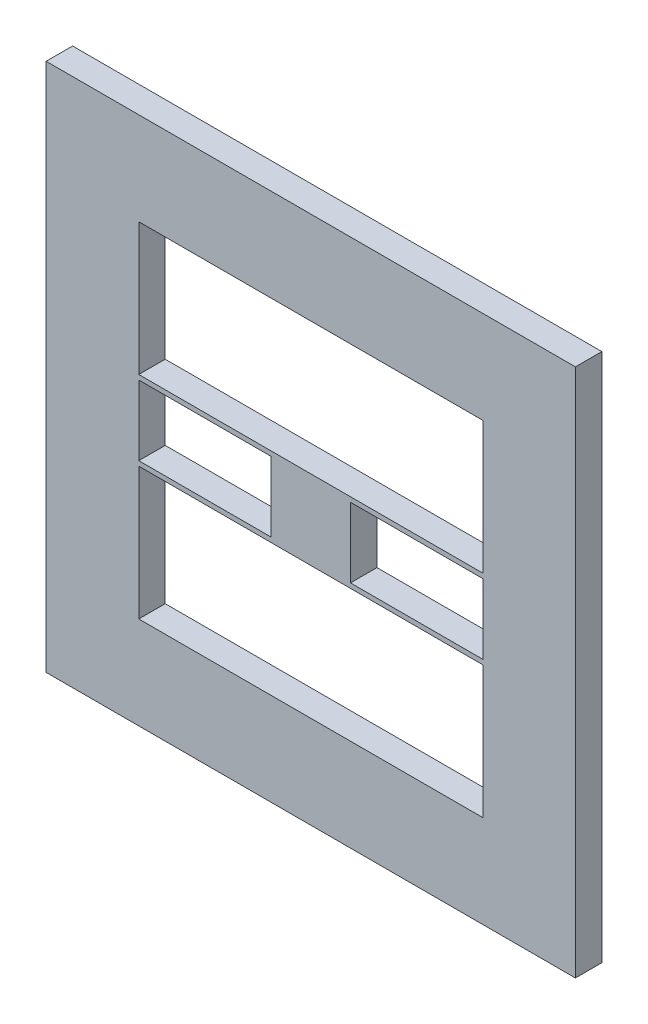
from build123d import *

# Parameters (mm, degrees)
SKETCH1_W      = 0.15
SKETCH1_H      = 0.15
EXTRUDE1_DEPTH = 0.05
SKETCH2_W      = 0.25
SKETCH2_H      = 0.009
EXTRUDE2_DEPTH = 0.05
SKETCH3_W      = 1
SKETCH3_H      = 1
SKETCH3_W_2    = 0.65
SKETCH3_H_2    = 0.65
EXTRUDE3_DEPTH = 0.05


with BuildPart() as part:
    # Sketch1 → Extrude1 (new body)
    with BuildSketch(Plane.XY):
        Rectangle(SKETCH1_W, SKETCH1_H)
    extrude(amount=EXTRUDE1_DEPTH)

    # Sketch2 → Extrude2 (add)
    with BuildSketch(Plane.XY.offset(0.05)):
        with Locations((0.2, 0.0705)):
            Rectangle(SKETCH2_W, SKETCH2_H)
        with Locations((-0.2, 0.0705)):
            Rectangle(SKETCH2_W, SKETCH2_H)
        with Locations((-0.2, -0.0705)):
            Rectangle(SKETCH2_W, SKETCH2_H)
        with Locations((0.2, -0.0705)):
            Rectangle(SKETCH2_W, SKETCH2_H)
    extrude(amount=-EXTRUDE2_DEPTH)

    # Sketch3 → Extrude3 (add)
    with BuildSketch(Plane.XY.offset(0.05)):
        Rectangle(SKETCH3_W, SKETCH3_H)
        Rectangle(SKETCH3_W_2, SKETCH3_H_2, mode=Mode.SUBTRACT)
    extrude(amount=-EXTRUDE3_DEPTH)


solid = part.part
